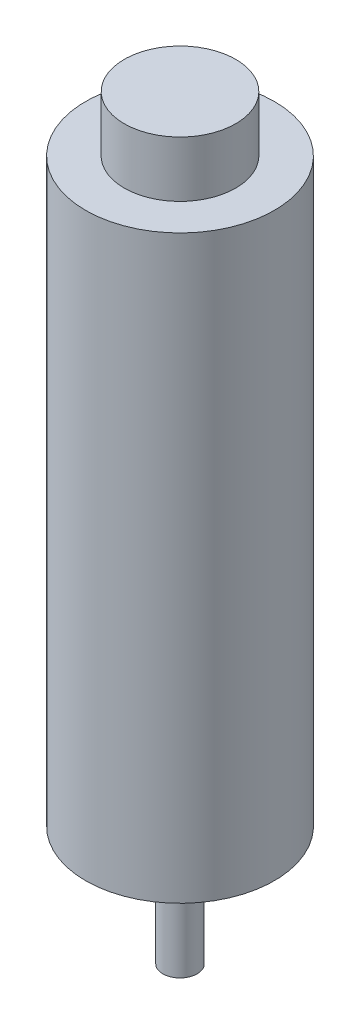
from build123d import *

# Parameters (mm, degrees)
SKETCH1_R           = 11
BOSS_EXTRUDE1_DEPTH = 33.835
SKETCH2_R           = 6.5
BOSS_EXTRUDE2_DEPTH = 6.5
SKETCH3_R           = 5
BOSS_EXTRUDE3_DEPTH = 1
SKETCH4_R           = 3.5
BOSS_EXTRUDE4_DEPTH = 2
SKETCH5_R           = 2
BOSS_EXTRUDE5_DEPTH = 10.9


with BuildPart() as part:
    # Sketch1 → Boss-Extrude1 (new body, symmetric)
    with BuildSketch(Plane(origin=(0, 0, 0), x_dir=(1, 0, 0), z_dir=(0, 1, 0))):
        Circle(SKETCH1_R)
    extrude(amount=BOSS_EXTRUDE1_DEPTH, both=True)

    # Sketch2 → Boss-Extrude2 (add)
    with BuildSketch(Plane(origin=(0, 33.835, 0), x_dir=(1, 0, 0), z_dir=(0, 1, 0))):
        Circle(SKETCH2_R)
    extrude(amount=BOSS_EXTRUDE2_DEPTH)

    # Sketch3 → Boss-Extrude3 (add)
    with BuildSketch(Plane.XZ.offset(33.835)):
        Circle(SKETCH3_R)
    extrude(amount=BOSS_EXTRUDE3_DEPTH)

    # Sketch4 → Boss-Extrude4 (add)
    with BuildSketch(Plane(origin=(0, -34.835, 0), x_dir=(-1, 0, 0), z_dir=(0, -1, 0))):
        Circle(SKETCH4_R)
    extrude(amount=BOSS_EXTRUDE4_DEPTH)

    # Sketch5 → Boss-Extrude5 (add)
    with BuildSketch(Plane.XZ.offset(36.835)):
        Circle(SKETCH5_R)
    extrude(amount=BOSS_EXTRUDE5_DEPTH)


solid = part.part
